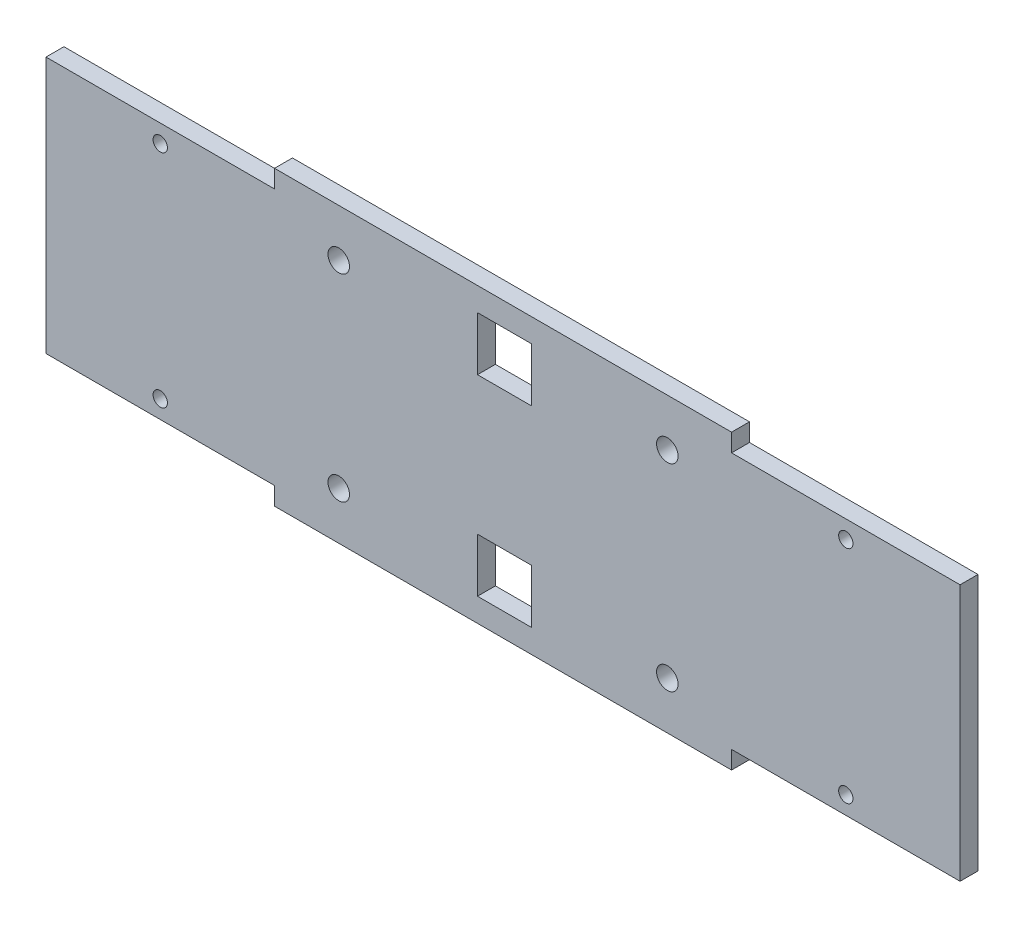
from build123d import *

# Parameters (mm, degrees)
SKETCH1_R           = 3
SKETCH1_W           = 15
SKETCH1_H           = 15
BOSS_EXTRUDE1_DEPTH = 5
SKETCH2_R           = 1.5
CUT_EXTRUDE1_DEPTH  = 185
SKETCH3_R           = 2
CUT_EXTRUDE2_DEPTH  = 10


with BuildPart() as part:
    # Sketch1 → Boss-Extrude1 (new body)
    with BuildSketch(Plane.XY):
        Polygon((191.25, 71.637645579), (255, 71.637645579), (255, 0), (191.25, 0), (191.25, -5), (127.5, -5), (63.75, -5), (63.75, 0), (0, 0), (0, 71.637645579), (63.75, 71.637645579), (63.75, 76.637645579), (127.5, 76.637645579), (191.25, 76.637645579), align=None)
        with Locations((81.6684273, 63.35852795)):
            Circle(SKETCH1_R, mode=Mode.SUBTRACT)
        with Locations((173.3315727, 63.35852795)):
            Circle(SKETCH1_R, mode=Mode.SUBTRACT)
        with Locations((81.6684273, 8.27911763)):
            Circle(SKETCH1_R, mode=Mode.SUBTRACT)
        with Locations((173.3315727, 8.27911763)):
            Circle(SKETCH1_R, mode=Mode.SUBTRACT)
        with Locations((127.870410973, 62.57941032)):
            Rectangle(SKETCH1_W, SKETCH1_H, mode=Mode.SUBTRACT)
        with Locations((127.870410973, 9.058235259)):
            Rectangle(SKETCH1_W, SKETCH1_H, mode=Mode.SUBTRACT)
    extrude(amount=BOSS_EXTRUDE1_DEPTH)

    # Sketch2 → Cut-Extrude1 (cut)
    with BuildSketch(Plane(origin=(0, 0, 0), x_dir=(-1, 0, 0), z_dir=(0, 0, -1))):
        with Locations((-31.875, 5)):
            Circle(SKETCH2_R)
        with Locations((-31.875, 66.637645579)):
            Circle(SKETCH2_R)
        with Locations((-223.125, 66.637645579)):
            Circle(SKETCH2_R)
        with Locations((-223.125, 5)):
            Circle(SKETCH2_R)
    extrude(amount=-CUT_EXTRUDE1_DEPTH, mode=Mode.SUBTRACT)

    # Sketch3 → Cut-Extrude2 (cut)
    with BuildSketch(Plane(origin=(0, 0, 0), x_dir=(-1, 0, 0), z_dir=(0, 0, -1))):
        with Locations((-31.875, 5)):
            Circle(SKETCH3_R)
        with Locations((-31.875, 66.637645579)):
            Circle(SKETCH3_R)
        with Locations((-223.125, 5)):
            Circle(SKETCH3_R)
        with Locations((-223.125, 66.637645579)):
            Circle(SKETCH3_R)
    extrude(amount=-CUT_EXTRUDE2_DEPTH, mode=Mode.SUBTRACT)


solid = part.part
